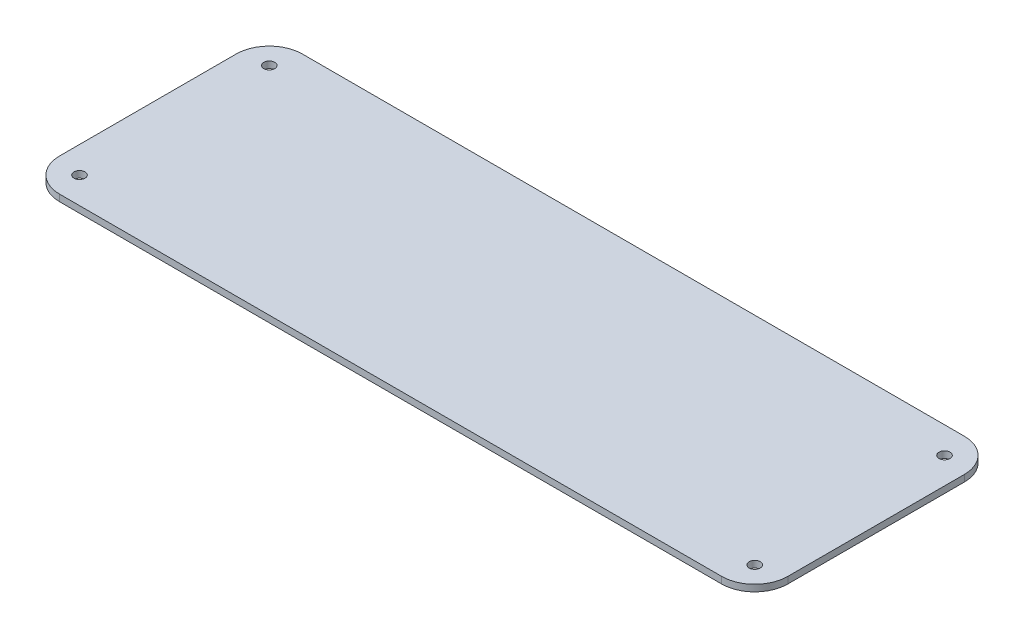
from build123d import *

# Parameters (mm, degrees)
ESQUISSE1_W      = 330
ESQUISSE1_H      = 110
ESQUISSE1_R      = 2.5
EXTRUSION1_DEPTH = 3
CONG_2_R         = 15


with BuildPart() as part:
    # Esquisse1 → Extrusion1 (new body)
    with BuildSketch(Plane(origin=(0, 0, 0), x_dir=(1, 0, 0), z_dir=(0, 1, 0))):
        with Locations((165, 55)):
            Rectangle(ESQUISSE1_W, ESQUISSE1_H)
        with Locations((12, 98)):
            Circle(ESQUISSE1_R, mode=Mode.SUBTRACT)
        with Locations((318, 98)):
            Circle(ESQUISSE1_R, mode=Mode.SUBTRACT)
        with Locations((318, 12)):
            Circle(ESQUISSE1_R, mode=Mode.SUBTRACT)
        with Locations((12, 12)):
            Circle(ESQUISSE1_R, mode=Mode.SUBTRACT)
    extrude(amount=EXTRUSION1_DEPTH)

    # Congé2
    cong_2_edges = [part.edges().sort_by_distance(p)[0] for p in [
        (0, 1.5, -110),
        (330, 1.5, -110),
        (330, 1.5, 0),
        (0, 1.5, 0),
    ]]
    fillet(cong_2_edges, radius=CONG_2_R)


solid = part.part
